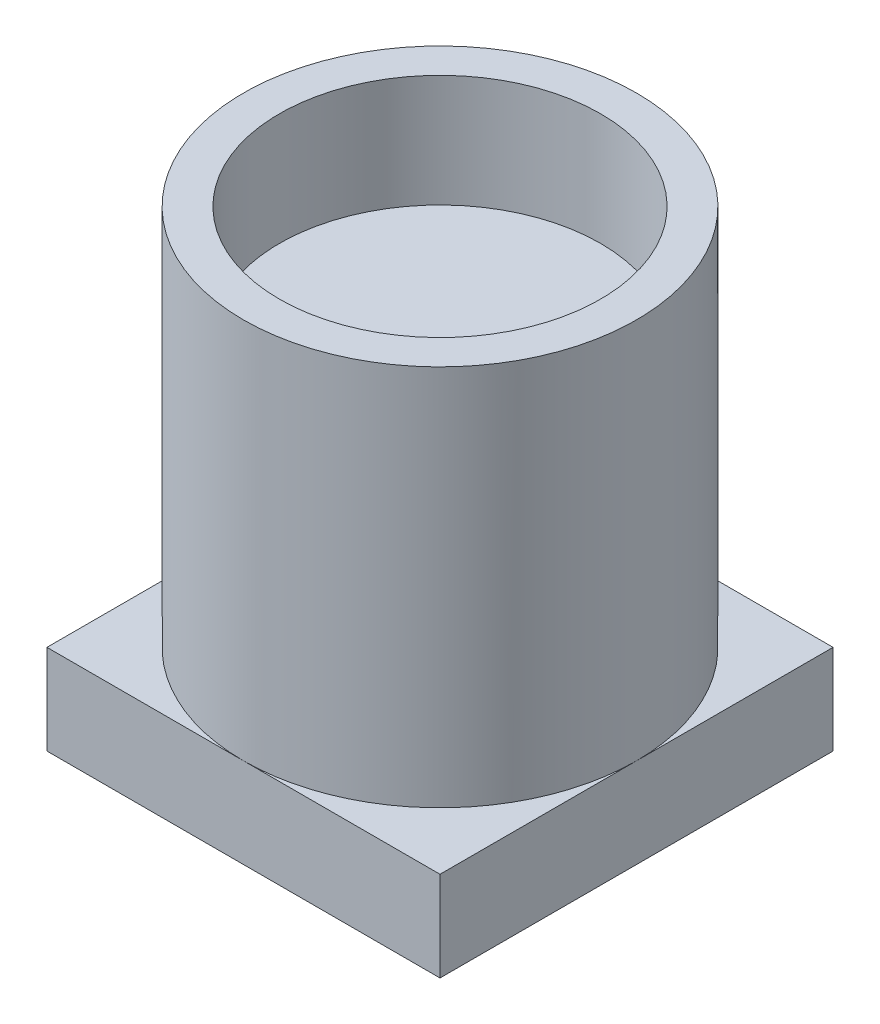
from build123d import *

# Parameters (mm, degrees)
SKETCH1_W           = 3.5
SKETCH1_H           = 3.5
BOSS_EXTRUDE1_DEPTH = 0.8
SKETCH2_R           = 1.75
BOSS_EXTRUDE2_DEPTH = 3.4
SKETCH4_R           = 1.43
CUT_EXTRUDE1_DEPTH  = 1


with BuildPart() as part:
    # Sketch1 → Boss-Extrude1 (new body)
    with BuildSketch(Plane(origin=(0, 0, 0), x_dir=(1, 0, 0), z_dir=(0, 1, 0))):
        Rectangle(SKETCH1_W, SKETCH1_H)
    extrude(amount=BOSS_EXTRUDE1_DEPTH)

    # Sketch2 → Boss-Extrude2 (add)
    with BuildSketch(Plane(origin=(0, 0.8, 0), x_dir=(1, 0, 0), z_dir=(0, 1, 0))):
        Circle(SKETCH2_R)
    extrude(amount=BOSS_EXTRUDE2_DEPTH)

    # Sketch4 → Cut-Extrude1 (cut)
    with BuildSketch(Plane(origin=(0, 4.2, 0), x_dir=(1, 0, 0), z_dir=(0, 1, 0))):
        Circle(SKETCH4_R)
    extrude(amount=-CUT_EXTRUDE1_DEPTH, mode=Mode.SUBTRACT)


solid = part.part
